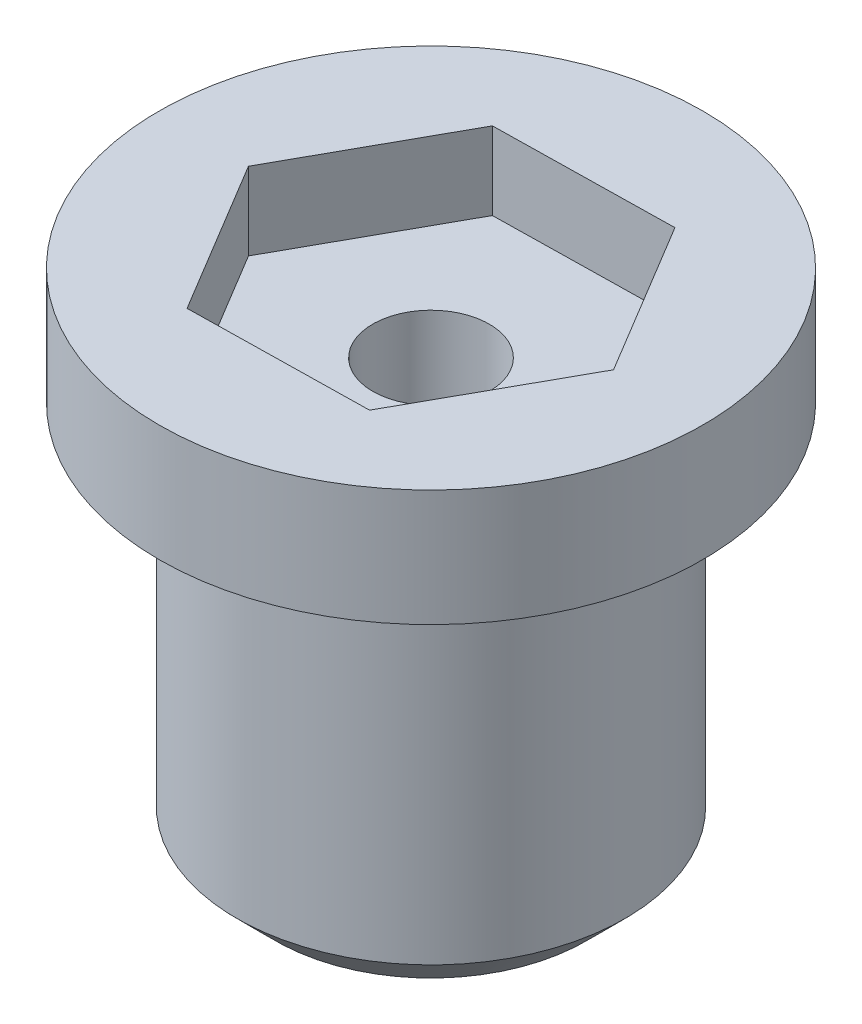
from build123d import *

# Parameters (mm, degrees)
SKETCH3_R          = 1.5
CUT_EXTRUDE1_DEPTH = 14
CUT_EXTRUDE2_DEPTH = 2


with BuildPart() as part:
    # Sketch1 → Revolve1 (revolve)
    with BuildSketch(Plane.XY):
        Polygon((7, 13), (0, 13), (0, 10), (0, 0), (4, 0), (5, 1), (5, 10), (7, 10), align=None)
    revolve(axis=Axis((0, -4.570663127, 0), (0, 1, 0)))

    # Sketch3 → Cut-Extrude1 (cut, through all)
    with BuildSketch(Plane(origin=(0, 13, 0), x_dir=(1, 0, 0), z_dir=(0, 1, 0))):
        Circle(SKETCH3_R)
    extrude(amount=-CUT_EXTRUDE1_DEPTH, mode=Mode.SUBTRACT)

    # Sketch4 → Cut-Extrude2 (cut)
    with BuildSketch(Plane(origin=(0, 13, 0), x_dir=(1, 0, 0), z_dir=(0, 1, 0))):
        Polygon((2.239533559, 4.039532494), (-2.37857098, 3.959259202), (-4.618104539, -0.080273292), (-2.239533559, -4.039532494), (2.37857098, -3.959259202), (4.618104539, 0.080273292), align=None)
    extrude(amount=-CUT_EXTRUDE2_DEPTH, mode=Mode.SUBTRACT)


solid = part.part
